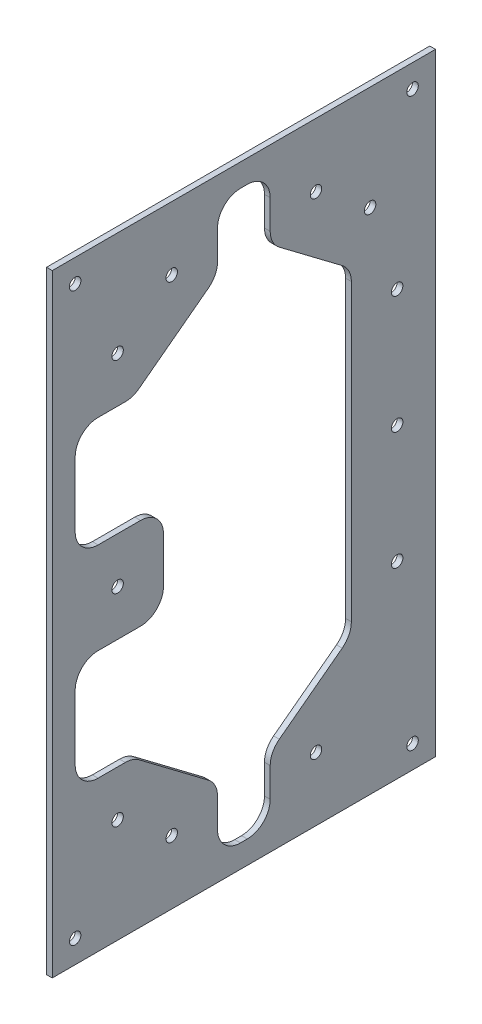
from build123d import *

# Parameters (mm, degrees)
SKETCH1_W           = 212.5
SKETCH1_H           = 339.725
SKETCH1_R           = 3.175
BOSS_EXTRUDE1_DEPTH = 3.175
CUT_EXTRUDE1_DEPTH  = 4.175


with BuildPart() as part:
    # Sketch1 → Boss-Extrude1 (new body)
    with BuildSketch(Plane(origin=(0, 0, 0), x_dir=(0, 0, -1), z_dir=(1, 0, 0))):
        with Locations((106.25, -169.8625)):
            Rectangle(SKETCH1_W, SKETCH1_H)
        with Locations((12.7, -12.7)):
            Circle(SKETCH1_R, mode=Mode.SUBTRACT)
        with Locations((199.8, -12.7)):
            Circle(SKETCH1_R, mode=Mode.SUBTRACT)
        with Locations((66.25, -35.2425)):
            Circle(SKETCH1_R, mode=Mode.SUBTRACT)
        with Locations((146.25, -35.2425)):
            Circle(SKETCH1_R, mode=Mode.SUBTRACT)
        with Locations((176.25, -57.8625)):
            Circle(SKETCH1_R, mode=Mode.SUBTRACT)
        with Locations((36.25, -57.8625)):
            Circle(SKETCH1_R, mode=Mode.SUBTRACT)
        with Locations((191.25, -104.5325)):
            Circle(SKETCH1_R, mode=Mode.SUBTRACT)
        with Locations((36.25, -169.8625)):
            Circle(SKETCH1_R, mode=Mode.SUBTRACT)
        with Locations((191.25, -169.8625)):
            Circle(SKETCH1_R, mode=Mode.SUBTRACT)
        with Locations((36.25, -281.8625)):
            Circle(SKETCH1_R, mode=Mode.SUBTRACT)
        with Locations((66.25, -304.4825)):
            Circle(SKETCH1_R, mode=Mode.SUBTRACT)
        with Locations((12.7, -327.025)):
            Circle(SKETCH1_R, mode=Mode.SUBTRACT)
        with Locations((199.8, -327.025)):
            Circle(SKETCH1_R, mode=Mode.SUBTRACT)
        with Locations((146.25, -304.4825)):
            Circle(SKETCH1_R, mode=Mode.SUBTRACT)
        with Locations((191.25, -235.1925)):
            Circle(SKETCH1_R, mode=Mode.SUBTRACT)
    extrude(amount=BOSS_EXTRUDE1_DEPTH)

    # Sketch2 → Cut-Extrude1 (cut, through all)
    with BuildSketch(Plane(origin=(3.175, 0, 0), x_dir=(0, 0, -1), z_dir=(1, 0, 0))):
        with BuildLine():
            Line((165.85, -88.161695758), (165.85, -251.563304242))
            ThreePointArc((165.85, -251.563304242), (164.516472011, -257.22840036), (160.795934799, -261.703801323))
            Line((160.795934799, -261.703801323), (125.904065201, -288.012271))
            ThreePointArc((125.904065201, -288.012271), (122.183527989, -292.487671963), (120.85, -298.152768081))
            Line((120.85, -298.152768081), (120.85, -314.325))
            ThreePointArc((120.85, -314.325), (117.130256121, -323.305256121), (108.15, -327.025))
            Line((108.15, -327.025), (104.35, -327.025))
            ThreePointArc((104.35, -327.025), (95.369743879, -323.305256121), (91.65, -314.325))
            Line((91.65, -314.325), (91.65, -298.152768081))
            ThreePointArc((91.65, -298.152768081), (90.316472011, -292.487671963), (86.595934799, -288.012271))
            Line((86.595934799, -288.012271), (48.147303392, -259.022002919))
            ThreePointArc((48.147303392, -259.022002919), (44.532850149, -257.119362682), (40.501368593, -256.4625))
            Line((40.501368593, -256.4625), (25.4, -256.4625))
            ThreePointArc((25.4, -256.4625), (16.419743879, -252.742756121), (12.7, -243.7625))
            Line((12.7, -243.7625), (12.7, -207.9625))
            ThreePointArc((12.7, -207.9625), (16.419743879, -198.982243879), (25.4, -195.2625))
            Line((25.4, -195.2625), (48.95, -195.2625))
            ThreePointArc((48.95, -195.2625), (57.930256121, -191.542756121), (61.65, -182.5625))
            Line((61.65, -182.5625), (61.65, -157.1625))
            ThreePointArc((61.65, -157.1625), (57.930256121, -148.182243879), (48.95, -144.4625))
            Line((48.95, -144.4625), (25.4, -144.4625))
            ThreePointArc((25.4, -144.4625), (16.419743879, -140.742756121), (12.7, -131.7625))
            Line((12.7, -131.7625), (12.7, -95.9625))
            ThreePointArc((12.7, -95.9625), (16.419743879, -86.982243879), (25.4, -83.2625))
            Line((25.4, -83.2625), (40.501368593, -83.2625))
            ThreePointArc((40.501368593, -83.2625), (44.532850149, -82.605637318), (48.147303392, -80.702997081))
            Line((48.147303392, -80.702997081), (86.595934799, -51.712729))
            ThreePointArc((86.595934799, -51.712729), (90.316472011, -47.237328037), (91.65, -41.572231919))
            Line((91.65, -41.572231919), (91.65, -25.4))
            ThreePointArc((91.65, -25.4), (95.369743879, -16.419743879), (104.35, -12.7))
            Line((104.35, -12.7), (108.15, -12.7))
            ThreePointArc((108.15, -12.7), (117.130256121, -16.419743879), (120.85, -25.4))
            Line((120.85, -25.4), (120.85, -41.572231919))
            ThreePointArc((120.85, -41.572231919), (122.183527989, -47.237328037), (125.904065201, -51.712729))
            Line((125.904065201, -51.712729), (160.795934799, -78.021198677))
            ThreePointArc((160.795934799, -78.021198677), (164.516472011, -82.49659964), (165.85, -88.161695758))
        make_face()
    extrude(amount=-CUT_EXTRUDE1_DEPTH, mode=Mode.SUBTRACT)


solid = part.part
